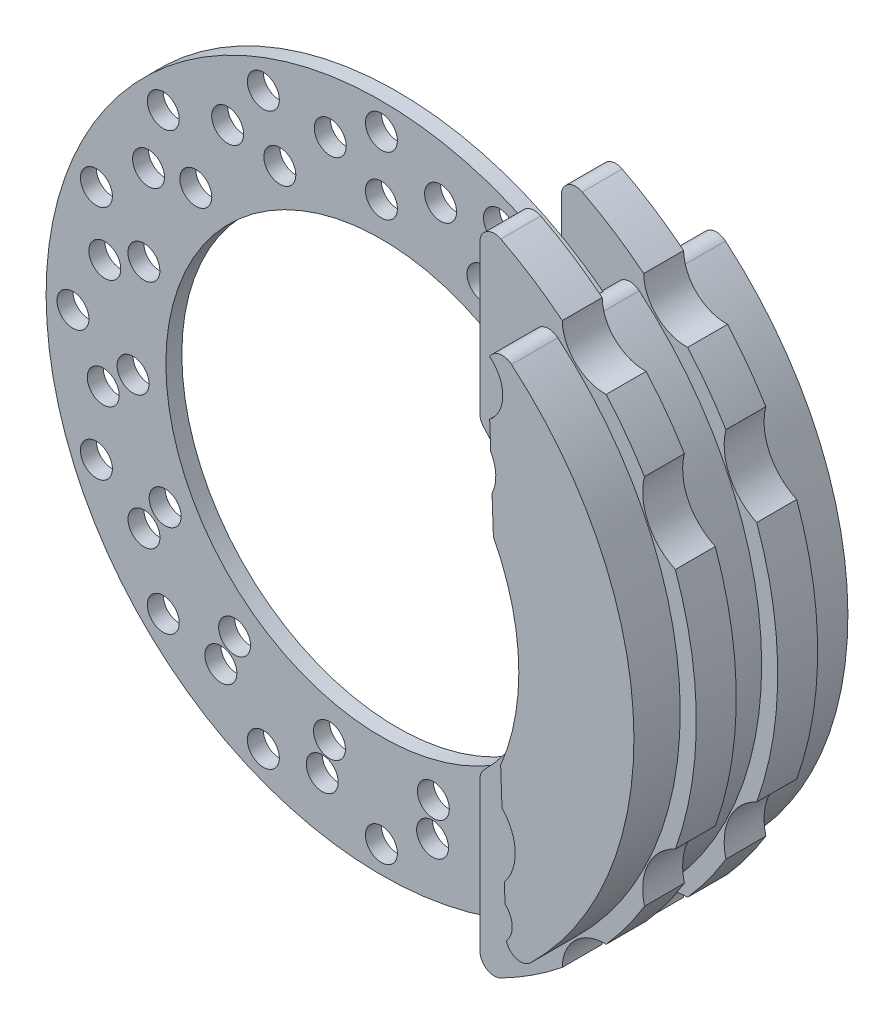
from build123d import *

# Parameters (mm, degrees)
SKETCH2_R                = 210
SKETCH2_R_2              = 135
BOSS_EXTRUDE1_DEPTH      = 10
CUT_EXTRUDE1_DEPTH       = 10
CUT_EXTRUDE1_DEPTH_BACK  = 10
SKETCH3_R                = 10
BOSS_EXTRUDE2_DEPTH      = 25
BOSS_EXTRUDE3_DEPTH      = 25
BOSS_EXTRUDE4_DEPTH      = 67
BOSS_EXTRUDE4_DEPTH_BACK = 67


with BuildPart() as part:
    # Sketch2 → Boss-Extrude1 (new body)
    with BuildSketch(Plane.XY):
        Circle(SKETCH2_R)
        Circle(SKETCH2_R_2, mode=Mode.SUBTRACT)
    extrude(amount=BOSS_EXTRUDE1_DEPTH)

    # Sketch3 → Cut-Extrude1 (cut, two sides: drawn at the far end of the back side and taken through both)
    with BuildSketch(Plane.XY.offset(-CUT_EXTRUDE1_DEPTH_BACK)):
        with Locations((0, 193.197162002)):
            Circle(SKETCH3_R)
        with Locations((37.071880295, 173.226532384)):
            Circle(SKETCH3_R)
        with Locations((100.540875426, 145.853653362)):
            Circle(SKETCH3_R)
        with Locations((148.703433678, 96.275877783)):
            Circle(SKETCH3_R)
        with Locations((174.227242153, 32.040972553)):
            Circle(SKETCH3_R)
        with Locations((173.226532384, -37.071880295)):
            Circle(SKETCH3_R)
        with Locations((145.853653362, -100.540875426)):
            Circle(SKETCH3_R)
        with Locations((96.275877783, -148.703433678)):
            Circle(SKETCH3_R)
        with Locations((32.040972554, -174.227242153)):
            Circle(SKETCH3_R)
        with Locations((-37.071880295, -173.226532384)):
            Circle(SKETCH3_R)
        with Locations((-100.540875426, -145.853653362)):
            Circle(SKETCH3_R)
        with Locations((-148.703433678, -96.275877783)):
            Circle(SKETCH3_R)
        with Locations((-174.227242153, -32.040972553)):
            Circle(SKETCH3_R)
        with Locations((-173.226532384, 37.071880295)):
            Circle(SKETCH3_R)
        with Locations((-145.853653362, 100.540875426)):
            Circle(SKETCH3_R)
        with Locations((-96.275877783, 148.703433678)):
            Circle(SKETCH3_R)
        with Locations((-32.040972553, 174.227242153)):
            Circle(SKETCH3_R)
        with Locations((73.933353078, 178.490903713)):
            Circle(SKETCH3_R)
        with Locations((136.611023358, 136.611023358)):
            Circle(SKETCH3_R)
        with Locations((178.490903713, 73.933353078)):
            Circle(SKETCH3_R)
        with Locations((193.197162002, 0)):
            Circle(SKETCH3_R)
        with Locations((178.490903713, -73.933353078)):
            Circle(SKETCH3_R)
        with Locations((136.611023358, -136.611023358)):
            Circle(SKETCH3_R)
        with Locations((73.933353078, -178.490903713)):
            Circle(SKETCH3_R)
        with Locations((0, -193.197162002)):
            Circle(SKETCH3_R)
        with Locations((-73.933353078, -178.490903713)):
            Circle(SKETCH3_R)
        with Locations((-136.611023358, -136.611023358)):
            Circle(SKETCH3_R)
        with Locations((-178.490903713, -73.933353078)):
            Circle(SKETCH3_R)
        with Locations((-193.197162002, 0)):
            Circle(SKETCH3_R)
        with Locations((-178.490903713, 73.933353078)):
            Circle(SKETCH3_R)
        with Locations((-136.611023358, 136.611023358)):
            Circle(SKETCH3_R)
        with Locations((-73.933353078, 178.490903713)):
            Circle(SKETCH3_R)
        with Locations((0, 156.410432221)):
            Circle(SKETCH3_R)
        with Locations((63.617854144, 142.888039883)):
            Circle(SKETCH3_R)
        with Locations((116.235603356, 104.659007353)):
            Circle(SKETCH3_R)
        with Locations((148.75516078, 48.333481654)):
            Circle(SKETCH3_R)
        with Locations((155.553599508, -16.349342119)):
            Circle(SKETCH3_R)
        with Locations((135.45540772, -78.20521611)):
            Circle(SKETCH3_R)
        with Locations((91.935745364, -126.538697764)):
            Circle(SKETCH3_R)
        with Locations((32.519557425, -152.992489006)):
            Circle(SKETCH3_R)
        with Locations((-32.519557425, -152.992489006)):
            Circle(SKETCH3_R)
        with Locations((-91.935745364, -126.538697764)):
            Circle(SKETCH3_R)
        with Locations((-135.45540772, -78.20521611)):
            Circle(SKETCH3_R)
        with Locations((-155.553599508, -16.349342119)):
            Circle(SKETCH3_R)
        with Locations((-148.75516078, 48.333481654)):
            Circle(SKETCH3_R)
        with Locations((-116.235603356, 104.659007353)):
            Circle(SKETCH3_R)
        with Locations((-63.617854143, 142.888039883)):
            Circle(SKETCH3_R)
    extrude(amount=CUT_EXTRUDE1_DEPTH + CUT_EXTRUDE1_DEPTH_BACK, mode=Mode.SUBTRACT)



with BuildPart() as body_2:
    # Sketch4 → Boss-Extrude2 (new body)
    with BuildSketch(Plane.XY.offset(13)):
        with BuildLine():
            Line((89.699423037, 192.385548243), (89.699423037, 99.043714713))
            ThreePointArc((89.699423037, 99.043714713), (90.387508707, 95.592326562), (92.346551963, 92.668683018))
            ThreePointArc((92.346551963, 92.668683018), (130.825725573, 0), (92.346551963, -92.668683018))
            ThreePointArc((92.346551963, -92.668683018), (90.387508707, -95.592326562), (89.699423037, -99.043714713))
            Line((89.699423037, -99.043714713), (89.699423037, -192.385548243))
            ThreePointArc((89.699423037, -192.385548243), (94.00759833, -200.065833454), (102.807596575, -200.393226445))
            ThreePointArc((102.807596575, -200.393226445), (122.675577525, -188.885017398), (141.268660314, -175.413832783))
            ThreePointArc((141.268660314, -175.413832783), (149.513380795, -156.502698139), (168.781213285, -149.129974051))
            ThreePointArc((168.781213285, -149.129974051), (181.513487561, -133.340545041), (192.773608207, -116.469665997))
            ThreePointArc((192.773608207, -116.469665997), (195.045606898, -92.634226865), (212.083561399, -75.811675242))
            ThreePointArc((212.083561399, -75.811675242), (225.226213214, 0), (212.083561399, 75.811675242))
            ThreePointArc((212.083561399, 75.811675242), (195.045606898, 92.634226865), (192.773608207, 116.469665997))
            ThreePointArc((192.773608207, 116.469665997), (181.513487561, 133.340545041), (168.781213285, 149.129974051))
            ThreePointArc((168.781213285, 149.129974051), (149.513380795, 156.502698139), (141.268660314, 175.413832783))
            ThreePointArc((141.268660314, 175.413832783), (122.675577525, 188.885017398), (102.807596575, 200.393226445))
            ThreePointArc((102.807596575, 200.393226445), (94.00759833, 200.065833454), (89.699423037, 192.385548243))
        make_face()
    extrude(amount=BOSS_EXTRUDE2_DEPTH)


with BuildPart() as body_3:
    # Sketch6 → Boss-Extrude3 (new body)
    with BuildSketch(Plane(origin=(0, 0, -13), x_dir=(-1, 0, 0), z_dir=(0, 0, -1))):
        with BuildLine():
            Line((-89.699423037, -99.043714713), (-89.699423037, -192.385548243))
            ThreePointArc((-89.699423037, -192.385548243), (-94.00759833, -200.065833454), (-102.807596575, -200.393226445))
            ThreePointArc((-102.807596575, -200.393226445), (-122.675577525, -188.885017398), (-141.268660314, -175.413832783))
            ThreePointArc((-141.268660314, -175.413832783), (-149.513380795, -156.502698139), (-168.781213285, -149.129974051))
            ThreePointArc((-168.781213285, -149.129974051), (-181.513487561, -133.340545041), (-192.773608207, -116.469665997))
            ThreePointArc((-192.773608207, -116.469665997), (-195.045606898, -92.634226865), (-212.083561399, -75.811675242))
            ThreePointArc((-212.083561399, -75.811675242), (-225.226213214, 0), (-212.083561399, 75.811675242))
            ThreePointArc((-212.083561399, 75.811675242), (-195.045606898, 92.634226865), (-192.773608207, 116.469665997))
            ThreePointArc((-192.773608207, 116.469665997), (-181.513487561, 133.340545041), (-168.781213285, 149.129974051))
            ThreePointArc((-168.781213285, 149.129974051), (-149.513380795, 156.502698139), (-141.268660314, 175.413832783))
            ThreePointArc((-141.268660314, 175.413832783), (-122.675577525, 188.885017398), (-102.807596575, 200.393226445))
            ThreePointArc((-102.807596575, 200.393226445), (-94.00759833, 200.065833454), (-89.699423037, 192.385548243))
            Line((-89.699423037, 192.385548243), (-89.699423037, 99.043714713))
            ThreePointArc((-89.699423037, 99.043714713), (-90.387508707, 95.592326562), (-92.346551963, 92.668683018))
            ThreePointArc((-92.346551963, 92.668683018), (-130.825725573, 0), (-92.346551963, -92.668683018))
            ThreePointArc((-92.346551963, -92.668683018), (-90.387508707, -95.592326562), (-89.699423037, -99.043714713))
        make_face()
    extrude(amount=BOSS_EXTRUDE3_DEPTH)


with BuildPart() as part_1:
    add(part.part)

    add(body_2.part)  # Boss-Extrude4 merges body 2

    add(body_3.part)  # Boss-Extrude4 merges body 3
    # Sketch7 → Boss-Extrude4 (add, two sides: drawn at the far end of the back side and taken through both)
    with BuildSketch(Plane.XY.offset(-BOSS_EXTRUDE4_DEPTH_BACK)):
        with BuildLine():
            Line((124.797572435, 128.173439312), (125.442001569, 110.919091112))
            ThreePointArc((125.442001569, 110.919091112), (128.621769694, 99.926736137), (126.270819, 88.727815472))
            Line((126.270819, 88.727815472), (127.134644848, 65.599202612))
            ThreePointArc((127.134644848, 65.599202612), (142.961406409, 5.33943643), (131.673727115, -55.933021476))
            Line((131.673727115, -55.933021476), (132.528568771, -78.821085957))
            ThreePointArc((132.528568771, -78.821085957), (140.793126639, -98.20534295), (133.997533992, -118.152078436))
            Line((133.997533992, -118.152078436), (134.440437213, -130.010645939))
            ThreePointArc((134.440437213, -130.010645939), (138.90259856, -139.536805522), (135.321811068, -149.428042109))
            ThreePointArc((135.321811068, -149.428042109), (141.553905611, -156.063570567), (150.388109377, -153.866735539))
            ThreePointArc((150.388109377, -153.866735539), (215.00481878, 8.030171155), (138.491666876, 164.656047424))
            ThreePointArc((138.491666876, 164.656047424), (131.044013158, 166.615042764), (124.807721177, 162.096871567))
            ThreePointArc((124.807721177, 162.096871567), (132.998470182, 145.132703527), (124.797572435, 128.173439312))
        make_face()
    extrude(amount=BOSS_EXTRUDE4_DEPTH + BOSS_EXTRUDE4_DEPTH_BACK)


solid = part_1.part
